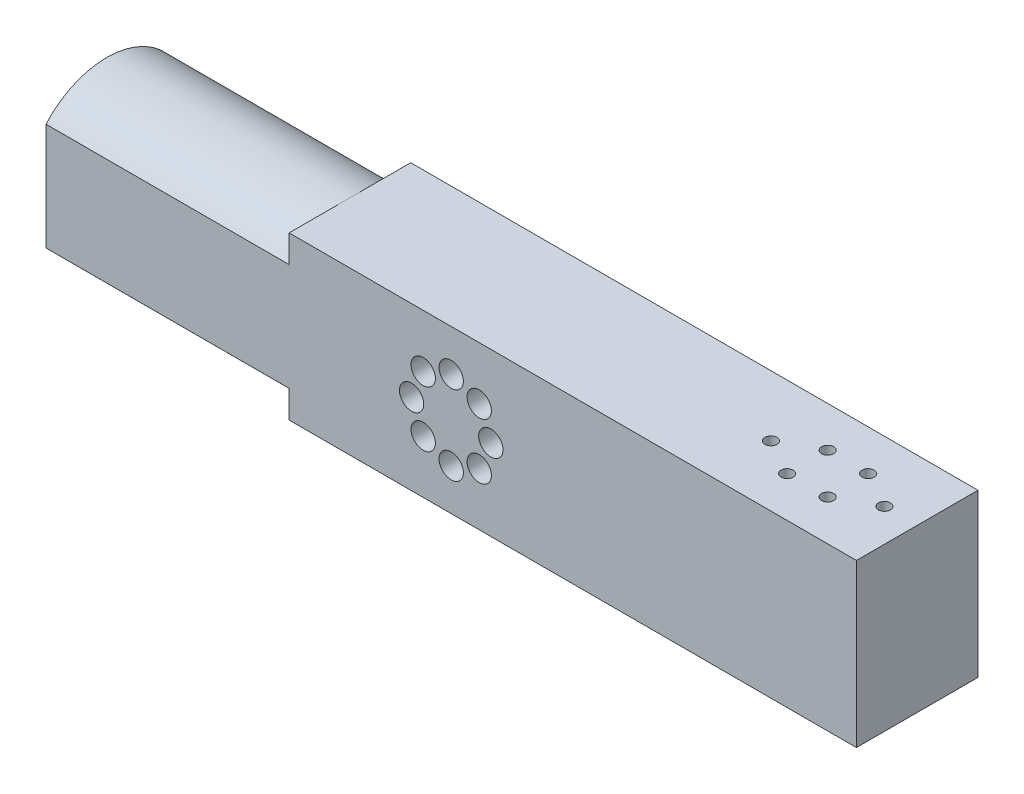
from build123d import *

# Parameters (mm, degrees)
CROQUIS1_W              = 200
CROQUIS1_H              = 40
CROQUIS1_R              = 2
SALIENTE_EXTRUIR1_DEPTH = 10
CROQUIS2_W              = 200
CROQUIS2_H              = 7
SALIENTE_EXTRUIR3_DEPTH = 20
CROQUIS3_W              = 84
CROQUIS3_H              = 26
SALIENTE_EXTRUIR4_DEPTH = 20
CROQUIS5_R              = 1.5
CORTAR_EXTRUIR1_DEPTH   = 10
CORTAR_EXTRUIR2_DEPTH   = 60
CROQUIS8_W              = 32
CROQUIS8_H              = 26
SALIENTE_EXTRUIR5_DEPTH = 20
CROQUIS7_R              = 3
CORTAR_EXTRUIR3_DEPTH   = 20


with BuildPart() as part:
    # Croquis1 → Saliente-Extruir1 (new body)
    with BuildSketch(Plane.XY):
        Rectangle(CROQUIS1_W, CROQUIS1_H)
        with Locations((0, 9.779)):
            Circle(CROQUIS1_R, mode=Mode.SUBTRACT)
        with Locations((6.914797213, 6.914797213)):
            Circle(CROQUIS1_R, mode=Mode.SUBTRACT)
        with Locations((9.779, 0)):
            Circle(CROQUIS1_R, mode=Mode.SUBTRACT)
        with Locations((6.914797213, -6.914797213)):
            Circle(CROQUIS1_R, mode=Mode.SUBTRACT)
        with Locations((0, -9.779)):
            Circle(CROQUIS1_R, mode=Mode.SUBTRACT)
        with Locations((-6.914797213, -6.914797213)):
            Circle(CROQUIS1_R, mode=Mode.SUBTRACT)
        with Locations((-9.779, 0)):
            Circle(CROQUIS1_R, mode=Mode.SUBTRACT)
        with Locations((-6.914797213, 6.914797213)):
            Circle(CROQUIS1_R, mode=Mode.SUBTRACT)
    extrude(amount=SALIENTE_EXTRUIR1_DEPTH)

    # Croquis2 → Saliente-Extruir3 (add)
    with BuildSketch(Plane.XY.offset(10)):
        with Locations((0, -16.5)):
            Rectangle(CROQUIS2_W, CROQUIS2_H)
        with Locations((0, 16.5)):
            Rectangle(CROQUIS2_W, CROQUIS2_H)
    extrude(amount=SALIENTE_EXTRUIR3_DEPTH)

    # Croquis3 → Saliente-Extruir4 (add)
    with BuildSketch(Plane.XY.offset(10)):
        with Locations((-58, 0)):
            Rectangle(CROQUIS3_W, CROQUIS3_H)
        with Locations((58, 0)):
            Rectangle(CROQUIS3_W, CROQUIS3_H)
    extrude(amount=SALIENTE_EXTRUIR4_DEPTH)

    # Croquis5 → Cortar-Extruir1 (cut)
    with BuildSketch(Plane(origin=(0, 20, 0), x_dir=(-1, 0, 0), z_dir=(0, -1, 0))):
        with Locations((-63.9, -15)):
            Circle(CROQUIS5_R)
        with Locations((-72.9, -10)):
            Circle(CROQUIS5_R)
        with Locations((-72.9, -20)):
            Circle(CROQUIS5_R)
        with Locations((-82.9, -20)):
            Circle(CROQUIS5_R)
        with Locations((-82.9, -10)):
            Circle(CROQUIS5_R)
        with Locations((-91.9, -15)):
            Circle(CROQUIS5_R)
    extrude(amount=CORTAR_EXTRUIR1_DEPTH, mode=Mode.SUBTRACT)

    # Croquis6 → Cortar-Extruir2 (cut)
    with BuildSketch(Plane.ZY.offset(100)):
        with BuildLine():
            Line((-8.93194877, 20), (-8.93194877, -20))
            Line((-8.93194877, -20), (0, -20))
            Line((0, -20), (0, -13.228756555))
            ThreePointArc((0, -13.228756555), (-5, 0), (0, 13.228756555))
            Line((0, 13.228756555), (0, 20))
            Line((0, 20), (-8.93194877, 20))
        make_face()
        with BuildLine():
            Line((30, -13.228756555), (30, -20))
            Line((30, -20), (38.93194877, -20))
            Line((38.93194877, -20), (38.93194877, 20))
            Line((38.93194877, 20), (30, 20))
            Line((30, 20), (30, 13.228756555))
            ThreePointArc((30, 13.228756555), (33.708286934, 7.071067812), (35, 0))
            ThreePointArc((35, 0), (33.708286934, -7.071067812), (30, -13.228756555))
        make_face()
        with BuildLine():
            ThreePointArc((30, -13.228756555), (23.228756555, -18.228756555), (15, -20))
            Line((15, -20), (30, -20))
            Line((30, -20), (30, -13.228756555))
        make_face()
        with BuildLine():
            Line((0, -13.228756555), (0, -20))
            Line((0, -20), (15, -20))
            ThreePointArc((15, -20), (6.771243445, -18.228756555), (0, -13.228756555))
        make_face()
        with BuildLine():
            Line((15, 20), (0, 20))
            Line((0, 20), (0, 13.228756555))
            ThreePointArc((0, 13.228756555), (6.771243445, 18.228756555), (15, 20))
        make_face()
        with BuildLine():
            Line((30, 20), (15, 20))
            ThreePointArc((15, 20), (23.228756555, 18.228756555), (30, 13.228756555))
            Line((30, 13.228756555), (30, 20))
        make_face()
    extrude(amount=-CORTAR_EXTRUIR2_DEPTH, mode=Mode.SUBTRACT)

    # Croquis8 → Saliente-Extruir5 (add)
    with BuildSketch(Plane.XY.offset(10)):
        Rectangle(CROQUIS8_W, CROQUIS8_H)
    extrude(amount=SALIENTE_EXTRUIR5_DEPTH)

    # Croquis7 → Cortar-Extruir3 (cut)
    with BuildSketch(Plane.XY.offset(10)):
        with Locations((0, 9.779)):
            Circle(CROQUIS7_R)
        with Locations((-6.914797213, 6.914797213)):
            Circle(CROQUIS7_R)
        with Locations((-9.779, 0)):
            Circle(CROQUIS7_R)
        with Locations((6.914797213, 6.914797213)):
            Circle(CROQUIS7_R)
        with Locations((9.779, 0)):
            Circle(CROQUIS7_R)
        with Locations((-6.914797213, -6.914797213)):
            Circle(CROQUIS7_R)
        with Locations((6.914797213, -6.914797213)):
            Circle(CROQUIS7_R)
        with Locations((0, -9.779)):
            Circle(CROQUIS7_R)
    extrude(amount=CORTAR_EXTRUIR3_DEPTH, mode=Mode.SUBTRACT)


solid = part.part
